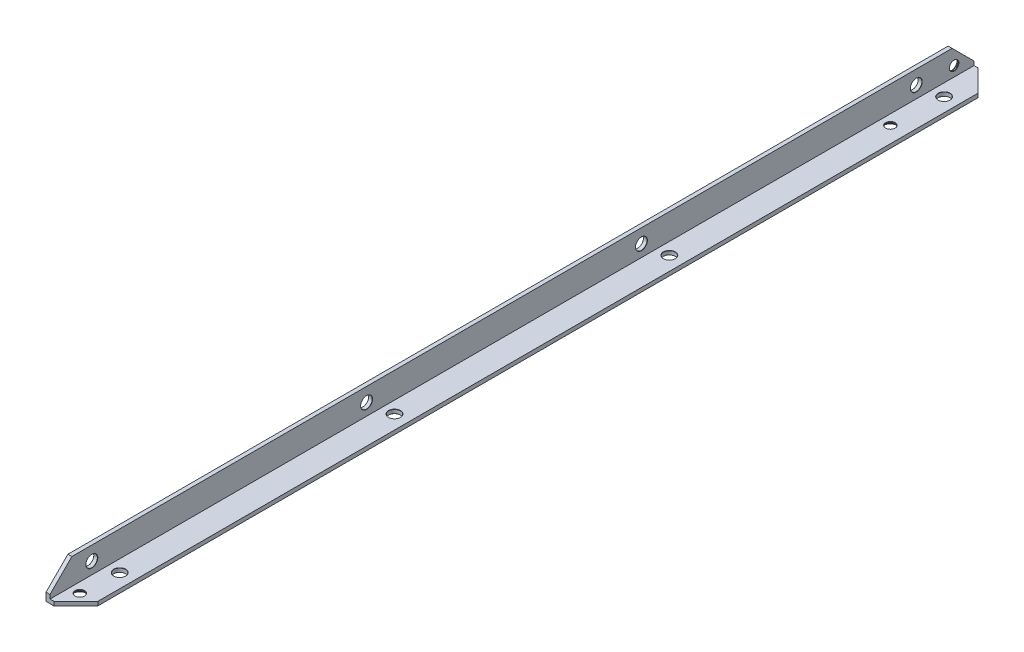
from build123d import *

# Parameters (mm, degrees)
EXTRUDE_1_DEPTH            = 464
CHAMFER_1_SIZE             = 11
HOLE_WIZARD_M41_AT_2_COUNT = 2
HOLE_WIZARD_M41_AT_2_PITCH = 407
HOLE_WIZARD_M51_AT_2_COUNT = 2
HOLE_WIZARD_M51_AT_2_PITCH = 138
HOLE_WIZARD_M51_AT_3_COUNT = 2
HOLE_WIZARD_M51_AT_3_PITCH = 276
HOLE_WIZARD_M51_AT_4_COUNT = 2
HOLE_WIZARD_M51_AT_4_PITCH = 414
HOLE_WIZARD_M52_AT_2_COUNT = 2
HOLE_WIZARD_M52_AT_2_PITCH = 138
HOLE_WIZARD_M52_AT_3_COUNT = 2
HOLE_WIZARD_M52_AT_3_PITCH = 276
HOLE_WIZARD_M52_AT_4_COUNT = 2
HOLE_WIZARD_M52_AT_4_PITCH = 414


with BuildPart() as part:
    # Эскиз1 → Бобышка-Вытянуть1 (new body)
    with BuildSketch(Plane.XY):
        Polygon((0, 0), (0, 15), (2, 15), (2, 2), (15, 2), (15, 0), align=None)
    extrude(amount=EXTRUDE_1_DEPTH)

    # Фаска1
    chamfer_1_edges = [part.edges().sort_by_distance(p)[0] for p in [
        (1, 15, 464),
        (1, 15, 0),
        (15, 1, 464),
        (15, 1, 0),
    ]]
    chamfer(chamfer_1_edges, length=CHAMFER_1_SIZE)

    # Эскиз2 → Зенковка для винта с потайной головкой M41 (revolve, cut)
    with BuildSketch(Plane(origin=(7, 0, 454), x_dir=(0, 0, -1), z_dir=(1, 0, 0))):
        Polygon((0, 0), (0, 2), (2.4, 2), (2.25, 1.85), (2.25, 1.45), (3.7, 0), align=None)
    hole_wizard_m41 = revolve(axis=Axis((7, -6.35, 454), (0, 1, 0)), mode=Mode.SUBTRACT)

    # Зенковка для винта с потайной головкой M41 at 2: Зенковка для винта с потайной головкой M41 ×2
    with Locations(*[(0, 0, -i * HOLE_WIZARD_M41_AT_2_PITCH) for i in range(1, HOLE_WIZARD_M41_AT_2_COUNT)]):
        add(hole_wizard_m41, mode=Mode.SUBTRACT)

    # Эскиз6 → Зенковка для винта с потайной головкой M42 (revolve, cut)
    with BuildSketch(Plane(origin=(0, 7, 10), x_dir=(0, 0, 1), z_dir=(0, 1, 0))):
        Polygon((0, 0), (0, 2), (2.4, 2), (2.25, 1.85), (2.25, 1.45), (3.7, 0), align=None)
    revolve(axis=Axis((-6.35, 7, 10), (1, 0, 0)), mode=Mode.SUBTRACT)

    # Эскиз8 → Отверстие с зазором M51 (revolve, cut)
    with BuildSketch(Plane(origin=(0, 8, 29), x_dir=(0, 0, 1), z_dir=(0, 1, 0))):
        Polygon((0, 0), (0, 2), (3, 2), (2.9, 1.9), (2.9, 0.1), (3, 0), align=None)
    hole_wizard_m51 = revolve(axis=Axis((-6.35, 8, 29), (1, 0, 0)), mode=Mode.SUBTRACT)

    # Отверстие с зазором M51 at 2: Отверстие с зазором M51 ×2
    with Locations(*[(0, 0, i * HOLE_WIZARD_M51_AT_2_PITCH) for i in range(1, HOLE_WIZARD_M51_AT_2_COUNT)]):
        add(hole_wizard_m51, mode=Mode.SUBTRACT)

    # Отверстие с зазором M51 at 3: Отверстие с зазором M51 ×2
    with Locations(*[(0, 0, i * HOLE_WIZARD_M51_AT_3_PITCH) for i in range(1, HOLE_WIZARD_M51_AT_3_COUNT)]):
        add(hole_wizard_m51, mode=Mode.SUBTRACT)

    # Отверстие с зазором M51 at 4: Отверстие с зазором M51 ×2
    with Locations(*[(0, 0, i * HOLE_WIZARD_M51_AT_4_PITCH) for i in range(1, HOLE_WIZARD_M51_AT_4_COUNT)]):
        add(hole_wizard_m51, mode=Mode.SUBTRACT)

    # Эскиз10 → Отверстие с зазором M52 (revolve, cut)
    with BuildSketch(Plane(origin=(8, 0, 21), x_dir=(0, 0, -1), z_dir=(1, 0, 0))):
        Polygon((0, 0), (0, 2), (3, 2), (2.9, 1.9), (2.9, 0.1), (3, 0), align=None)
    hole_wizard_m52 = revolve(axis=Axis((8, -6.35, 21), (0, 1, 0)), mode=Mode.SUBTRACT)

    # Отверстие с зазором M52 at 2: Отверстие с зазором M52 ×2
    with Locations(*[(0, 0, i * HOLE_WIZARD_M52_AT_2_PITCH) for i in range(1, HOLE_WIZARD_M52_AT_2_COUNT)]):
        add(hole_wizard_m52, mode=Mode.SUBTRACT)

    # Отверстие с зазором M52 at 3: Отверстие с зазором M52 ×2
    with Locations(*[(0, 0, i * HOLE_WIZARD_M52_AT_3_PITCH) for i in range(1, HOLE_WIZARD_M52_AT_3_COUNT)]):
        add(hole_wizard_m52, mode=Mode.SUBTRACT)

    # Отверстие с зазором M52 at 4: Отверстие с зазором M52 ×2
    with Locations(*[(0, 0, i * HOLE_WIZARD_M52_AT_4_PITCH) for i in range(1, HOLE_WIZARD_M52_AT_4_COUNT)]):
        add(hole_wizard_m52, mode=Mode.SUBTRACT)


solid = part.part
